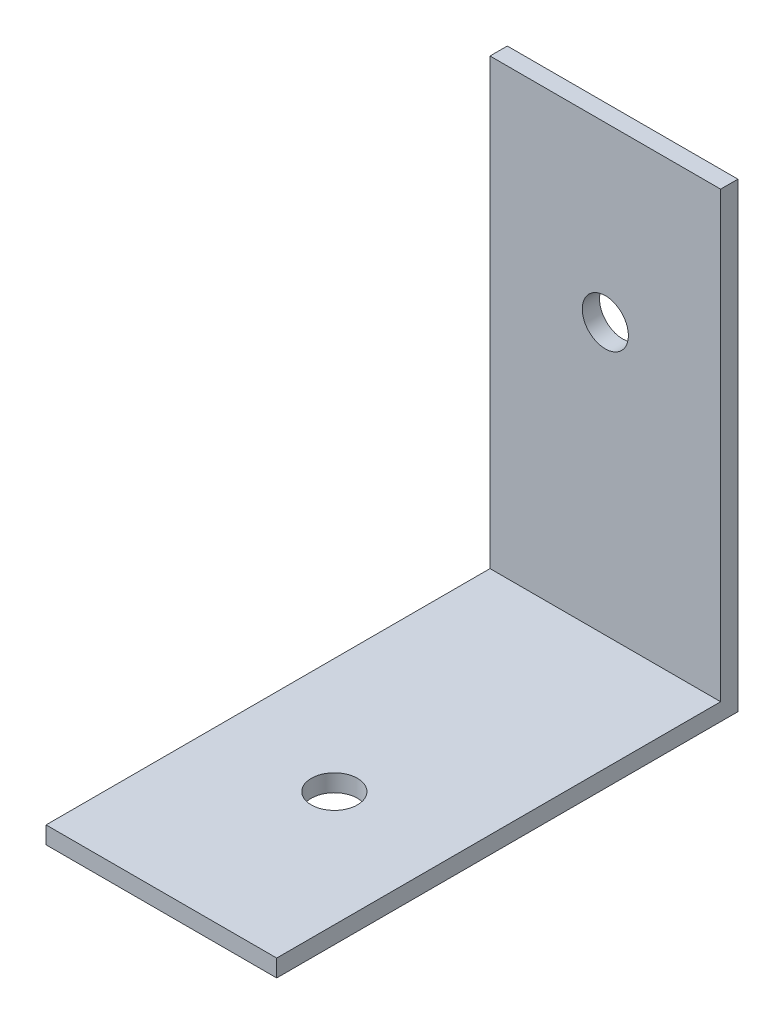
from build123d import *

# Parameters (mm, degrees)
SKETCH1_W           = 20
SKETCH1_H           = 40
SKETCH1_R           = 2
BOSS_EXTRUDE1_DEPTH = 1.5
SKETCH2_W           = 20
SKETCH2_H           = 1.5
BOSS_EXTRUDE2_DEPTH = 38.5
SKETCH3_R           = 2
CUT_EXTRUDE1_DEPTH  = 1.5


with BuildPart() as part:
    # Sketch1 → Boss-Extrude1 (new body)
    with BuildSketch(Plane(origin=(0, 0, 0), x_dir=(1, 0, 0), z_dir=(0, 1, 0))):
        Rectangle(SKETCH1_W, SKETCH1_H)
        with Locations((0, -5)):
            Circle(SKETCH1_R, mode=Mode.SUBTRACT)
    extrude(amount=BOSS_EXTRUDE1_DEPTH)

    # Sketch2 → Boss-Extrude2 (add)
    with BuildSketch(Plane(origin=(0, 1.5, 0), x_dir=(1, 0, 0), z_dir=(0, 1, 0))):
        with Locations((0, 19.25)):
            Rectangle(SKETCH2_W, SKETCH2_H)
    extrude(amount=BOSS_EXTRUDE2_DEPTH)

    # Sketch3 → Cut-Extrude1 (cut)
    with BuildSketch(Plane(origin=(0, 0, -20), x_dir=(-1, 0, 0), z_dir=(0, 0, -1))):
        with Locations((0, 25)):
            Circle(SKETCH3_R)
    extrude(amount=-CUT_EXTRUDE1_DEPTH, mode=Mode.SUBTRACT)


solid = part.part
